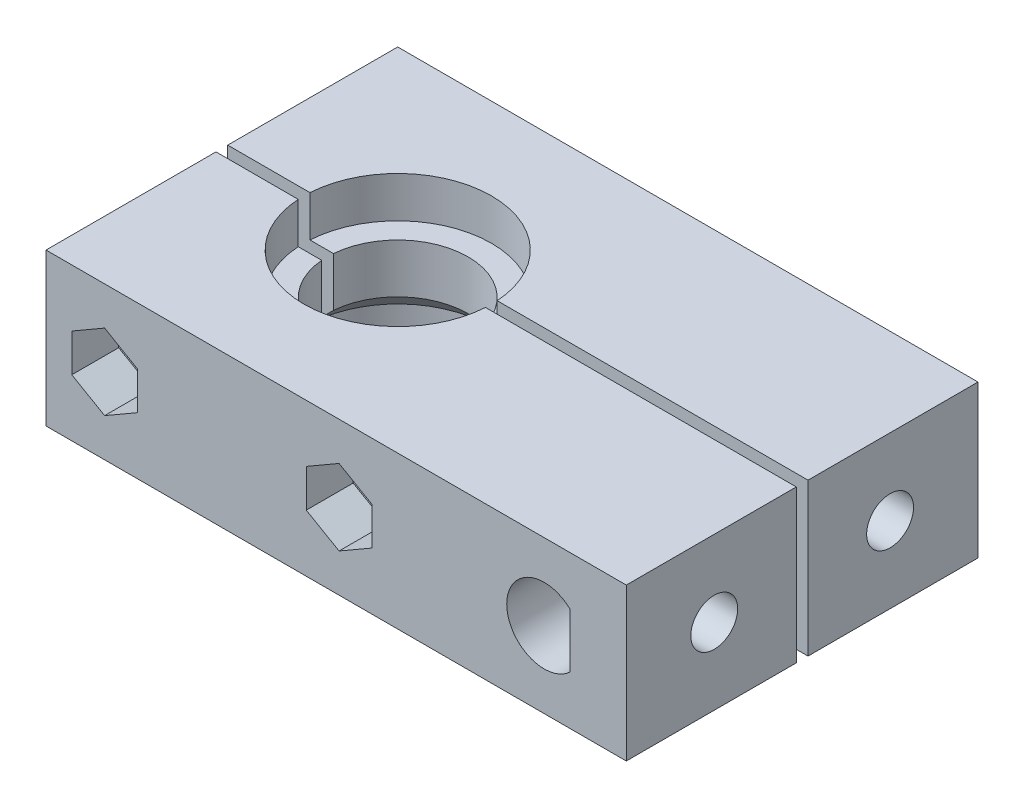
from build123d import *

# Parameters (mm, degrees)
SKIZZE1_W                            = 49.5
SKIZZE1_H                            = 13
SKIZZE1_R                            = 1.7
AUFSATZ_LINEAR_AUSTRAGEN1_DEPTH      = 15
FASE1_SIZE                           = 1.8
SCHNITT_LINEAR_AUSTRAGEN1_DEPTH      = 4
SKIZZE4_R                            = 2
SCHNITT_LINEAR_AUSTRAGEN2_DEPTH      = 4.8
SKIZZE5_W                            = 56.14798386
SKIZZE5_H                            = 1
SCHNITT_LINEAR_AUSTRAGEN3_DEPTH      = 7.5
SCHNITT_LINEAR_AUSTRAGEN3_DEPTH_BACK = 7.5


with BuildPart() as part:
    # Skizze1 → Aufsatz-Linear austragen1 (new body)
    with BuildSketch(Plane.XY):
        with Locations((-17.75, 0)):
            Rectangle(SKIZZE1_W, SKIZZE1_H)
        with Locations((-17.5, 0)):
            Circle(SKIZZE1_R, mode=Mode.SUBTRACT)
        with Locations((-37.5, 0)):
            Circle(SKIZZE1_R, mode=Mode.SUBTRACT)
        with BuildLine():
            Line((2.2, 2.323790008), (2.2, -2.323790008))
            ThreePointArc((2.2, -2.323790008), (-3.2, 0), (2.2, 2.323790008))
        make_face(mode=Mode.SUBTRACT)
    extrude(amount=AUFSATZ_LINEAR_AUSTRAGEN1_DEPTH)

    # Skizze2 → Schnitt-Rotation1 (revolve, cut)
    with BuildSketch(Plane.XY.offset(15)):
        Polygon((-35.5, 6.5), (-35.5, 3), (-33.5, 3), (-33.5, -3), (-35.5, -3), (-35.5, -6.5), (-27.5, -6.5), (-27.5, 6.5), align=None)
    revolve(axis=Axis((-27.5, -6.5, 15), (0, 1, 0)), mode=Mode.SUBTRACT)

    # Fase1
    fase1_edges = [part.edges().sort_by_distance(p)[0] for p in [
        (-27.5, -3, 9),
    ]]
    chamfer(fase1_edges, length=FASE1_SIZE)

    # Skizze3 → Schnitt-Linear austragen1 (cut)
    with BuildSketch(Plane.XY):
        Polygon((-14.7, -1.616580754), (-14.7, 1.616580754), (-17.5, 3.233161507), (-20.3, 1.616580754), (-20.3, -1.616580754), (-17.5, -3.233161507), align=None)
        Polygon((-37.5, -3.233161507), (-34.7, -1.616580754), (-34.7, 1.616580754), (-37.5, 3.233161507), (-40.3, 1.616580754), (-40.3, -1.616580754), align=None)
    extrude(amount=SCHNITT_LINEAR_AUSTRAGEN1_DEPTH, mode=Mode.SUBTRACT)

    # Skizze4 → Schnitt-Linear austragen2 (cut)
    with BuildSketch(Plane(origin=(7, 0, 0), x_dir=(0, 0, -1), z_dir=(1, 0, 0))):
        with Locations((-7.5, 0)):
            Circle(SKIZZE4_R)
    extrude(amount=-SCHNITT_LINEAR_AUSTRAGEN2_DEPTH, mode=Mode.SUBTRACT)


with BuildPart() as body_2:
    # Spiegeln1: mirrored copy
    add(part.part.mirror(Plane.XY.offset(15)))


with BuildPart() as schnitt_linear_austragen3_tool:
    # Skizze5 → Schnitt-Linear austragen3 (new body, two sides)
    with BuildSketch(Plane(origin=(0, 0, 0), x_dir=(1, 0, 0), z_dir=(0, 1, 0))) as schnitt_linear_austragen3_sk:
        with Locations((-20.374969748, -15)):
            Rectangle(SKIZZE5_W, SKIZZE5_H)
    extrude(amount=SCHNITT_LINEAR_AUSTRAGEN3_DEPTH)
    extrude(schnitt_linear_austragen3_sk.sketch, amount=-SCHNITT_LINEAR_AUSTRAGEN3_DEPTH_BACK)


with BuildPart() as part_1:
    add(part.part)

    # Schnitt-Linear austragen3: cut by schnitt_linear_austragen3_tool
    add(schnitt_linear_austragen3_tool.part, mode=Mode.SUBTRACT)


with BuildPart() as body_2_1:
    add(body_2.part)

    # Schnitt-Linear austragen3: cut by schnitt_linear_austragen3_tool
    add(schnitt_linear_austragen3_tool.part, mode=Mode.SUBTRACT)


solid = Compound([part_1.part, body_2_1.part])
